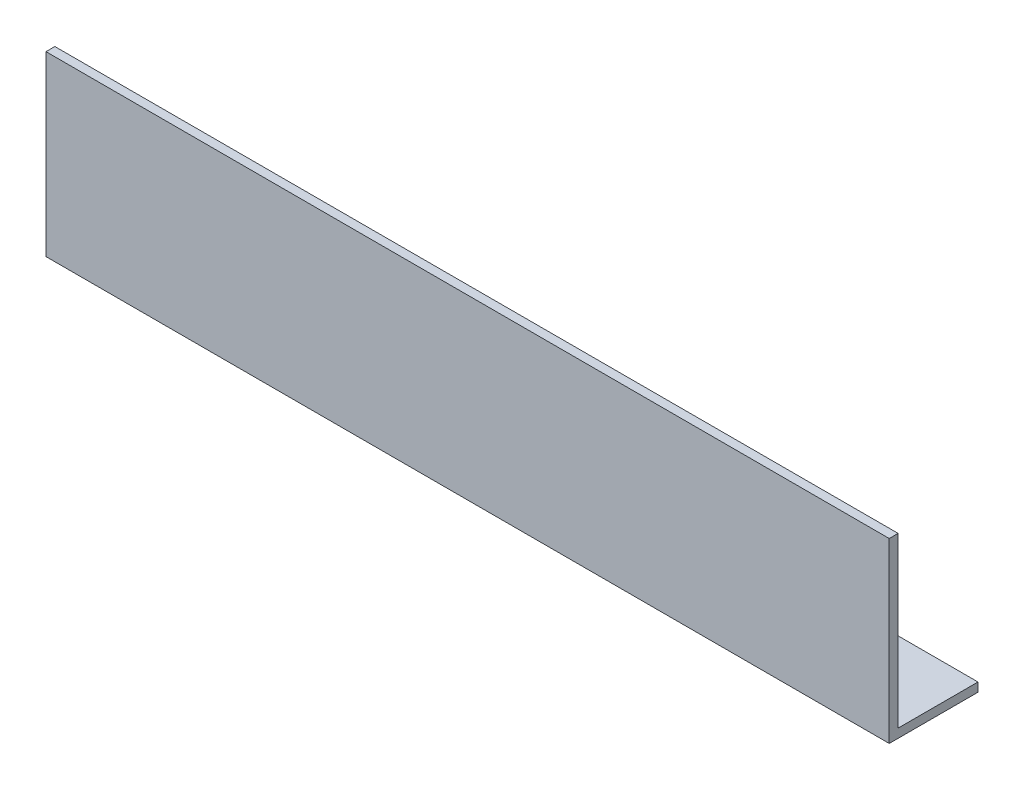
from build123d import *

# Parameters (mm, degrees)
EXTRUDE_1_DEPTH = 190


with BuildPart() as part:
    # Эскиз1 → Вытянуть-Тонкостенный1 (new body)
    with BuildSketch(Plane(origin=(0, 0, 0), x_dir=(0, 0, -1), z_dir=(1, 0, 0))):
        Polygon((0, 40), (0, 0), (20, 0), (20, 2), (2, 2), (2, 40), align=None)
    extrude(amount=EXTRUDE_1_DEPTH)


solid = part.part
